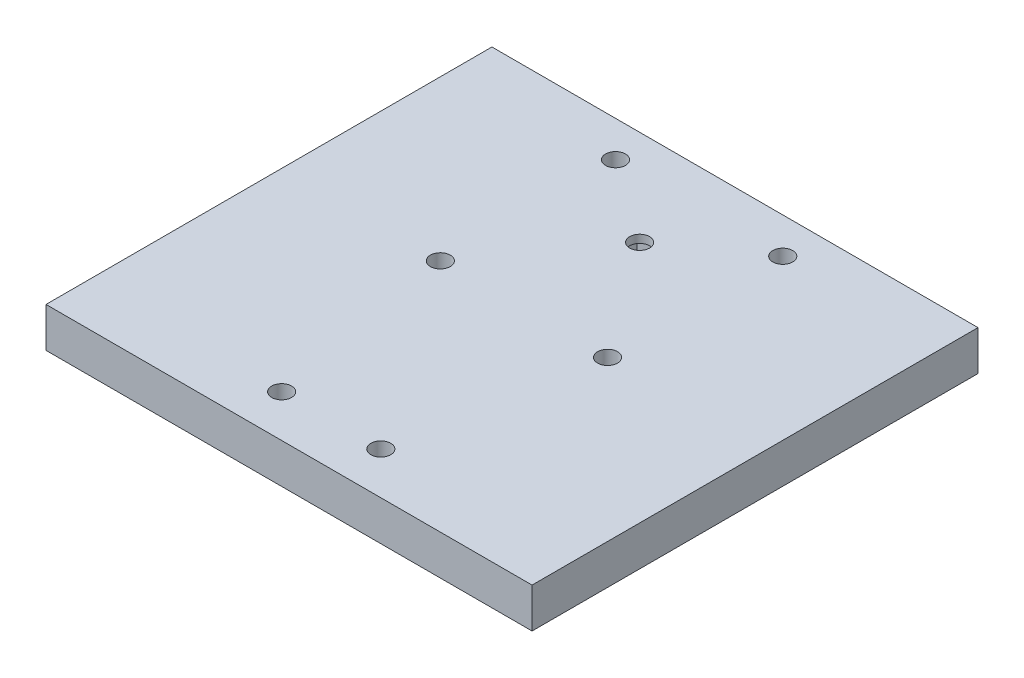
from build123d import *

# Parameters (mm, degrees)
BOSS_EXTRUDE1_DEPTH = 10
M6_TAPPED_HOLE2_D   = 5
M6_TAPPED_HOLE5_D   = 5
SKETCH14_W          = 15.472798768
SKETCH14_H          = 14.039377176
CUT_EXTRUDE1_DEPTH  = 8
M6_TAPPED_HOLE7_D   = 5


with BuildPart() as part:
    # Sketch2 → Boss-Extrude1 (new body)
    with BuildSketch(Plane(origin=(0, 0, 0), x_dir=(1, 0, 0), z_dir=(0, 1, 0))):
        Polygon((61.04, -67.5), (-61.04, -67.5), (-61.04, 37.5), (-61.04, 44.5), (61.04, 44.5), (61.04, 37.5), align=None)
    extrude(amount=BOSS_EXTRUDE1_DEPTH)

    # M6 Tapped Hole2 (through all)
    with Locations(Plane(origin=(0, 10, 0), x_dir=(1, 0, 0), z_dir=(0, 1, 0))):
        with Locations((-21, -8.5), (21, -8.5), (21, 35.5), (-21, 35.5)):
            Hole(M6_TAPPED_HOLE2_D / 2)

    # M6 Tapped Hole5 (through all)
    with Locations(Plane(origin=(0, 10, 0), x_dir=(1, 0, 0), z_dir=(0, 1, 0))):
        with Locations((-12.45, -56.9), (12.45, -56.9)):
            Hole(M6_TAPPED_HOLE5_D / 2)

    # Sketch14 → Cut-Extrude1 (cut)
    with BuildSketch(Plane(origin=(0, 0, 0), x_dir=(-1, 0, 0), z_dir=(0, -1, 0))):
        with Locations((0, 20.55)):
            Rectangle(SKETCH14_W, SKETCH14_H)
    extrude(amount=-CUT_EXTRUDE1_DEPTH, mode=Mode.SUBTRACT)

    # M6 Tapped Hole7 (through all)
    with Locations(Plane(origin=(0, 0, 0), x_dir=(-1, 0, 0), z_dir=(0, -1, 0))):
        with Locations((0, 20.55)):
            Hole(M6_TAPPED_HOLE7_D / 2)


solid = part.part
